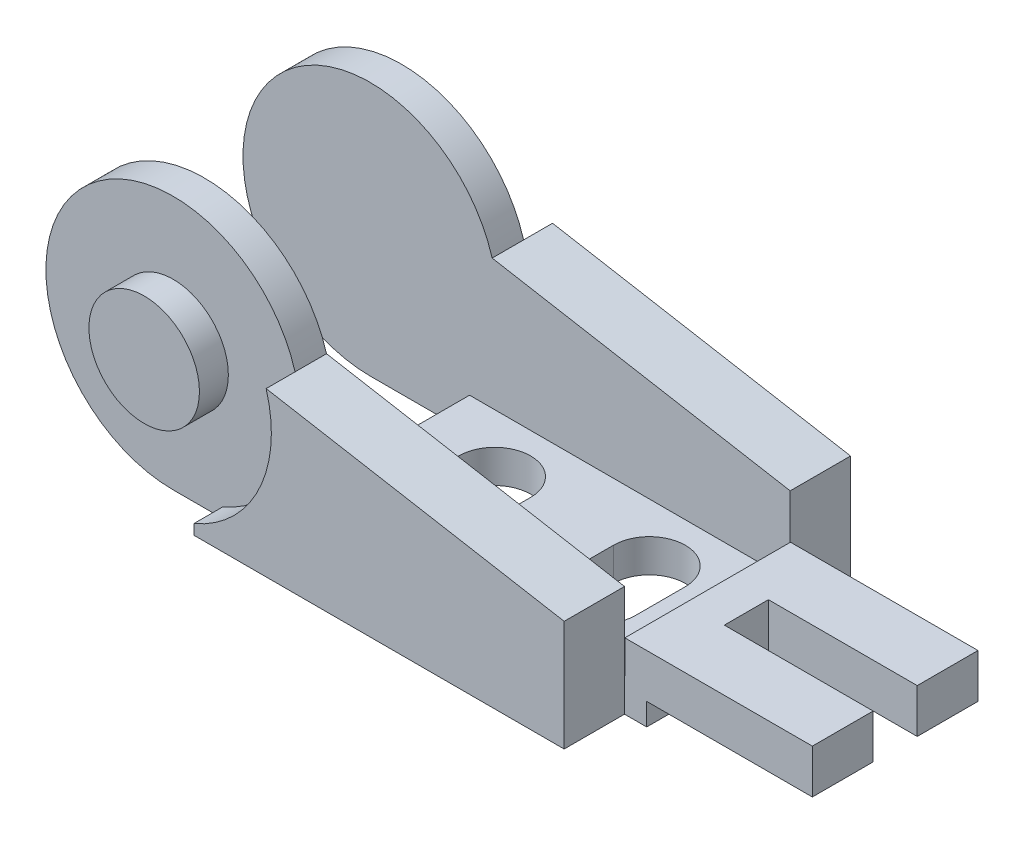
from build123d import *

# Parameters (mm, degrees)
EXTRUDE1_DEPTH             = 12.954
SKETCH3_R                  = 5
CUT_EXTRUDE1_DEPTH         = 2.6162
CUT_EXTRUDE2_DEPTH         = 7.493
EXTRUDE2_REACH             = 14.954
EXTRUDE2_DIRECTION_2_REACH = 14.954
SKETCH7_W                  = 13.462
SKETCH7_H                  = 3.9878
CUT_EXTRUDE3_DEPTH         = 6.9944
CUT_EXTRUDE4_DEPTH         = 3.9972


with BuildPart() as part:
    # Sketch2 → Extrude1 (new body, symmetric)
    with BuildSketch(Plane.XY):
        with BuildLine():
            Line((37.9984, -11.5062), (37.9984, -1.4986))
            Line((37.9984, -1.4986), (11.036020087, 3.255595043))
            ThreePointArc((11.036020087, 3.255595043), (-9.215534877, 6.889597621), (0, -11.5062))
            Line((0, -11.5062), (37.9984, -11.5062))
        make_face()
    extrude(amount=EXTRUDE1_DEPTH, both=True)

    # Sketch3 → Cut-Extrude1 (cut)
    with BuildSketch(Plane.XY.offset(12.954)):
        with BuildLine():
            Line((0, -11.5062), (4.495154191, -11.5062))
            Line((4.495154191, -11.5062), (4.495154191, -10.5918))
            ThreePointArc((4.495154191, -10.5918), (-2.293607342, 11.27528287), (0, -11.5062))
        make_face()
        Circle(SKETCH3_R, mode=Mode.SUBTRACT)
    cut_extrude1 = extrude(amount=-CUT_EXTRUDE1_DEPTH, mode=Mode.SUBTRACT)

    # Mirror1: Cut-Extrude1 across plane
    add(cut_extrude1.mirror(Plane.XY), mode=Mode.SUBTRACT)

    # Sketch4 → Cut-Extrude2 (cut, symmetric)
    with BuildSketch(Plane.XY):
        with BuildLine():
            Line((8.9916, -8.509), (37.9984, -8.509))
            Line((37.9984, -8.509), (37.9984, -1.4986))
            Line((37.9984, -1.4986), (11.036020087, 3.255595043))
            ThreePointArc((11.036020087, 3.255595043), (-9.215534877, 6.889597621), (0, -11.5062))
            Line((0, -11.5062), (8.9916, -11.5062))
            Line((8.9916, -11.5062), (8.9916, -8.509))
        make_face()
    extrude(amount=CUT_EXTRUDE2_DEPTH, both=True, mode=Mode.SUBTRACT)

    # Extrude2: up to this face of the body (flat: up to its plane)
    extrude2_end = Plane(part.part.faces().sort_by_distance((8.815484891, -1.610467544, -7.493))[0])
    # Sketch5 → Extrude2 (add, up to the picked face)
    with BuildSketch(Plane.XY, mode=Mode.PRIVATE) as extrude2_sk1:
        Polygon((54.991, -5.5118), (38.0238, -5.5118), (38.0238, -8.509), (37.9984, -8.509), (37.9984, -11.5062), (40.005, -11.5062), (40.005, -9.4996), (54.991, -9.4996), align=None)
    extrude2_tool1 = split(extrude(extrude2_sk1.sketch, amount=-EXTRUDE2_REACH, mode=Mode.PRIVATE), bisect_by=extrude2_end, keep=Keep.BOTH, mode=Mode.PRIVATE)
    add(extrude2_tool1.solids().sort_by_distance((46.083002, -7.674508, 0))[0])

    # Extrude2 direction 2: up to this face of the body (flat: up to its plane)
    extrude2_direction_2_end = Plane(part.part.faces().sort_by_distance((8.815484891, -1.610467544, 7.493))[0])
    # Sketch5 → Extrude2 direction 2 (add, up to the picked face)
    with BuildSketch(Plane.XY, mode=Mode.PRIVATE) as extrude2_direction_2_sk1:
        Polygon((54.991, -5.5118), (38.0238, -5.5118), (38.0238, -8.509), (37.9984, -8.509), (37.9984, -11.5062), (40.005, -11.5062), (40.005, -9.4996), (54.991, -9.4996), align=None)
    extrude2_direction_2_tool1 = split(extrude(extrude2_direction_2_sk1.sketch, amount=EXTRUDE2_DIRECTION_2_REACH, mode=Mode.PRIVATE), bisect_by=extrude2_direction_2_end, keep=Keep.BOTH, mode=Mode.PRIVATE)
    add(extrude2_direction_2_tool1.solids().sort_by_distance((46.083002, -7.674508, 0))[0])

    # Sketch7 → Cut-Extrude3 (cut, through all)
    with BuildSketch(Plane(origin=(0, -5.5118, 0), x_dir=(1, 0, 0), z_dir=(0, 1, 0))):
        with Locations((48.26, 0)):
            Rectangle(SKETCH7_W, SKETCH7_H)
    extrude(amount=-CUT_EXTRUDE3_DEPTH, mode=Mode.SUBTRACT)

    # Sketch8 → Cut-Extrude4 (cut, through all)
    with BuildSketch(Plane(origin=(0, -8.509, 0), x_dir=(1, 0, 0), z_dir=(0, 1, 0))):
        with BuildLine():
            Line((19.7612, 2.2479), (19.7612, -2.2479))
            ThreePointArc((19.7612, -2.2479), (16.51, -5.4991), (13.2588, -2.2479))
            Line((13.2588, -2.2479), (13.2588, 2.2479))
            ThreePointArc((13.2588, 2.2479), (16.51, 5.4991), (19.7612, 2.2479))
        make_face()
        with BuildLine():
            Line((33.7566, 2.2479), (33.7566, -2.2479))
            ThreePointArc((33.7566, -2.2479), (30.5054, -5.4991), (27.2542, -2.2479))
            Line((27.2542, -2.2479), (27.2542, 2.2479))
            ThreePointArc((27.2542, 2.2479), (30.5054, 5.4991), (33.7566, 2.2479))
        make_face()
    extrude(amount=-CUT_EXTRUDE4_DEPTH, mode=Mode.SUBTRACT)


solid = part.part
